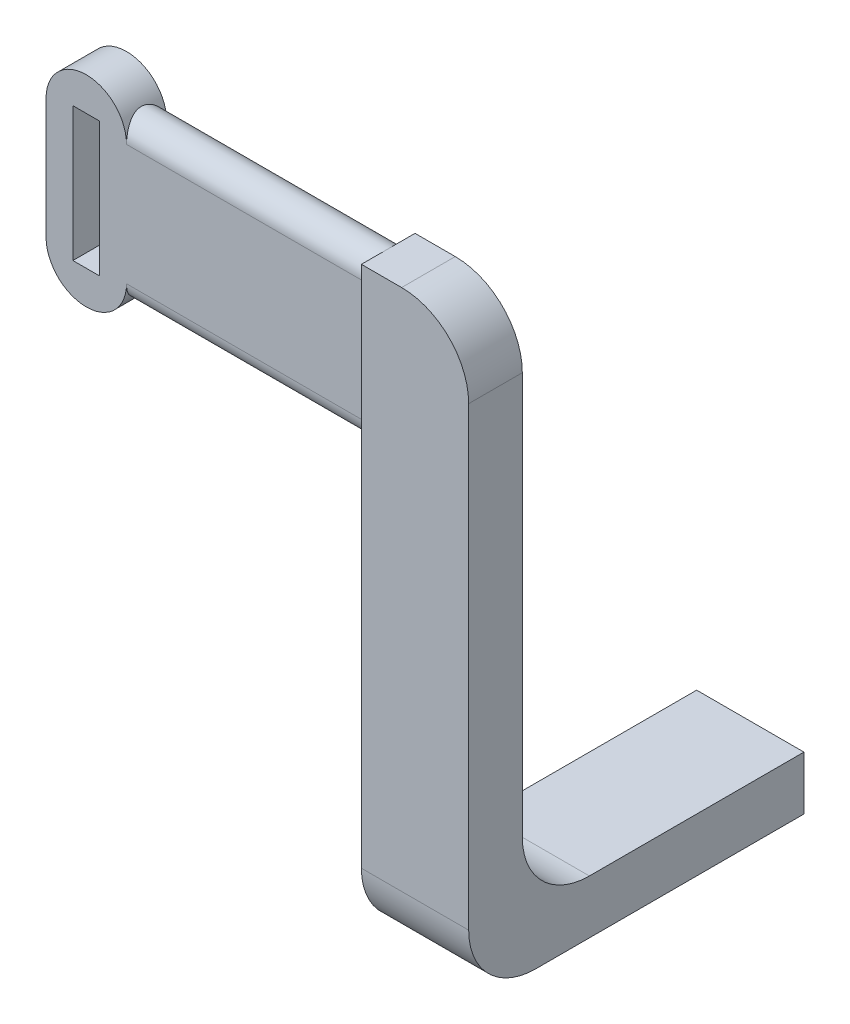
from build123d import *

# Parameters (mm, degrees)
ARM_FEATURE_SKETCH_W = 16
ARM_FEATURE_SKETCH_H = 8
ARM_FEATURE_DEPTH    = 50
TAB_FEATURE_SKETCH_W = 8
TAB_FEATURE_SKETCH_H = 25
TAB_FEATURE_DEPTH    = 5
LEG_FEATURE_SKETCH_W = 16
LEG_FEATURE_SKETCH_H = 8
LEG_FEATURE_DEPTH    = 80
SLOT_FEATURE_DEPTH   = 42
STRAP_FEATURE_DEPTH  = 6
STRAP_CUT_SKETCH_W   = 4
STRAP_CUT_SKETCH_H   = 20
STRAP_CUT_DEPTH      = 6
FILLET1_R            = 10
FILLET2_R            = 10
FILLET3_R            = 10


with BuildPart() as part:
    # Arm Feature Sketch → Arm Feature (new body)
    with BuildSketch(Plane.XY):
        Rectangle(ARM_FEATURE_SKETCH_W, ARM_FEATURE_SKETCH_H)
    extrude(amount=ARM_FEATURE_DEPTH)

    # Tab Feature Sketch → Tab Feature (cut)
    with BuildSketch(Plane(origin=(0, -4, 0), x_dir=(1, 0, 0), z_dir=(0, 1, 0))):
        with Locations((0, -12.5)):
            Rectangle(TAB_FEATURE_SKETCH_W, TAB_FEATURE_SKETCH_H)
    extrude(amount=TAB_FEATURE_DEPTH, mode=Mode.SUBTRACT)

    # Leg Feature Sketch → Leg Feature (add)
    with BuildSketch(Plane(origin=(0, 4, 0), x_dir=(1, 0, 0), z_dir=(0, 1, 0))):
        with Locations((0, -46)):
            Rectangle(LEG_FEATURE_SKETCH_W, LEG_FEATURE_SKETCH_H)
    extrude(amount=LEG_FEATURE_DEPTH)

    # Slot Feature Sketch → Slot Feature (add)
    with BuildSketch(Plane(origin=(-8, 0, 0), x_dir=(0, 0, -1), z_dir=(1, 0, 0))):
        with BuildLine():
            Line((-43.025235216, 81), (-43.025235216, 63))
            ThreePointArc((-43.025235216, 63), (-46.025235216, 60), (-49.025235216, 63))
            Line((-49.025235216, 63), (-49.025235216, 81))
            ThreePointArc((-49.025235216, 81), (-46.025235216, 84), (-43.025235216, 81))
        make_face()
    extrude(amount=-SLOT_FEATURE_DEPTH)

    # Strap Feature Sketch → Strap Feature (add)
    with BuildSketch(Plane(origin=(0, 0, 43.025235216), x_dir=(-1, 0, 0), z_dir=(0, 0, -1))):
        with BuildLine():
            Line((44, 63), (44, 81))
            ThreePointArc((44, 81), (50, 87), (56, 81))
            Line((56, 81), (56, 63))
            ThreePointArc((56, 63), (50, 57), (44, 63))
        make_face()
    extrude(amount=-STRAP_FEATURE_DEPTH)

    # Strap Cut Sketch → Strap Cut (cut)
    with BuildSketch(Plane.XY.offset(43.025235216)):
        with Locations((-50, 72)):
            Rectangle(STRAP_CUT_SKETCH_W, STRAP_CUT_SKETCH_H)
    extrude(amount=STRAP_CUT_DEPTH, mode=Mode.SUBTRACT)

    # Fillet1
    fillet1_edges = [part.edges().sort_by_distance(p)[0] for p in [
        (0, -4, 50),
    ]]
    fillet(fillet1_edges, radius=FILLET1_R)

    # Fillet2
    fillet2_edges = [part.edges().sort_by_distance(p)[0] for p in [
        (0, 4, 42),
    ]]
    fillet(fillet2_edges, radius=FILLET2_R)

    # Fillet3
    fillet3_edges = [part.edges().sort_by_distance(p)[0] for p in [
        (8, 84, 46),
    ]]
    fillet(fillet3_edges, radius=FILLET3_R)


solid = part.part
